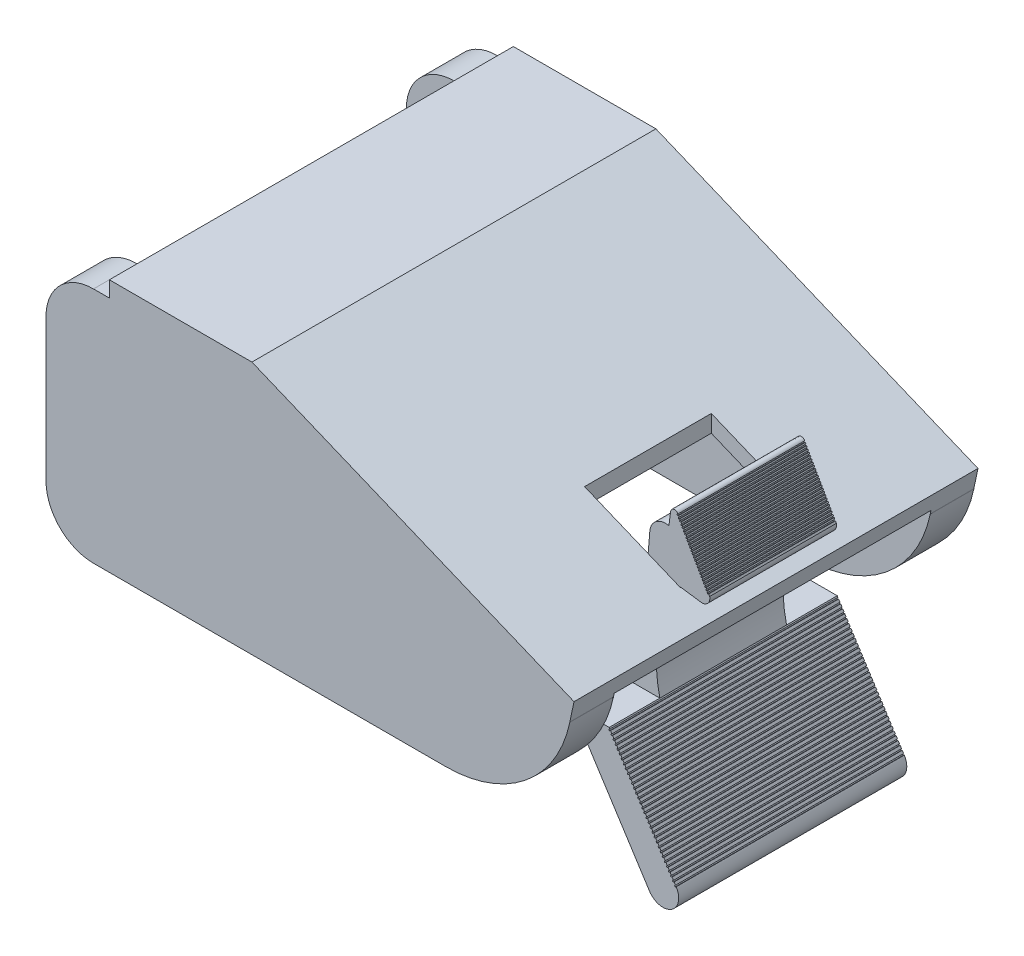
from build123d import *

# Parameters (mm, degrees)
RESSALTO_EXTRUS_O1_DEPTH      = 3.175
RESSALTO_EXTRUS_O2_DEPTH      = 37.3126
RESSALTO_EXTRUS_O2_DEPTH_BACK = 37.3126
RESSALTO_EXTRUS_O3_START      = -3.175
RESSALTO_EXTRUS_O3_DEPTH      = 3.175
CORTE_EXTRUS_O1_DEPTH         = 31.75
CORTE_EXTRUS_O1_DEPTH_BACK    = 31.75
RESSALTO_EXTRUS_O4_DEPTH      = 12.7
RESSALTO_EXTRUS_O4_DEPTH_BACK = 12.7
RESSALTO_EXTRUS_O5_DEPTH      = 12.7
RESSALTO_EXTRUS_O5_DEPTH_BACK = 12.7
RESSALTO_EXTRUS_O6_DEPTH      = 22.86
RESSALTO_EXTRUS_O6_DEPTH_BACK = 22.86
CORTE_EXTRUS_O2_DEPTH         = 12.7
CORTE_EXTRUS_O2_DEPTH_BACK    = 12.7
ESBO_O9_R                     = 2.54
RESSALTO_EXTRUS_O7_DEPTH      = 63.5


with BuildPart() as part:
    # Esboço1 → Ressalto-extrusão1 (new body)
    with BuildSketch(Plane.XY.offset(-40.4876)):
        with BuildLine():
            Line((79.375, -65.0875), (150.000604013, -65.0875))
            ThreePointArc((150.000604013, -65.0875), (165.991768653, -59.421801443), (174.848986961, -44.952275862))
            Line((174.848986961, -44.952275862), (174.848986961, -44.899230051))
            Line((174.848986961, -44.899230051), (175.685365082, -40.951741232))
            Line((175.685365082, -40.951741232), (111.125, -14.2875))
            Line((111.125, -14.2875), (82.55, -14.2875))
            Line((82.55, -14.2875), (82.55, -17.4625))
            Line((82.55, -17.4625), (79.375, -17.4625))
            ThreePointArc((79.375, -17.4625), (72.639807909, -20.252307909), (69.85, -26.9875))
            Line((69.85, -26.9875), (69.85, -55.5625))
            ThreePointArc((69.85, -55.5625), (72.639807909, -62.297692091), (79.375, -65.0875))
        make_face()
    extrude(amount=RESSALTO_EXTRUS_O1_DEPTH)

    # Esboço2 → Ressalto-extrusão2 (add, two sides: drawn at the far end of the back side and taken through both)
    with BuildSketch(Plane.XY.offset(-RESSALTO_EXTRUS_O2_DEPTH_BACK)):
        with BuildLine():
            Line((79.375, -65.0875), (150.000604013, -65.0875))
            ThreePointArc((150.000604013, -65.0875), (165.991768653, -59.421801443), (174.848986961, -44.952275862))
            Line((174.848986961, -44.952275862), (174.848986961, -44.899230051))
            Line((174.848986961, -44.899230051), (175.685365082, -40.951741232))
            Line((175.685365082, -40.951741232), (111.125, -14.2875))
            Line((111.125, -14.2875), (82.55, -14.2875))
            Line((82.55, -14.2875), (82.55, -17.4625))
            Line((82.55, -17.4625), (79.375, -17.4625))
            ThreePointArc((79.375, -17.4625), (72.639807909, -20.252307909), (69.85, -26.9875))
            Line((69.85, -26.9875), (69.85, -55.5625))
            ThreePointArc((69.85, -55.5625), (72.639807909, -62.297692091), (79.375, -65.0875))
        make_face()
    extrude(amount=RESSALTO_EXTRUS_O2_DEPTH + RESSALTO_EXTRUS_O2_DEPTH_BACK)

    # Esboço3 → Ressalto-extrusão3 (add)
    with BuildSketch(Plane.XY.offset(40.4876).offset(RESSALTO_EXTRUS_O3_START)):
        with BuildLine():
            Line((79.375, -65.0875), (150.000604013, -65.0875))
            ThreePointArc((150.000604013, -65.0875), (165.991768653, -59.421801443), (174.848986961, -44.952275862))
            Line((174.848986961, -44.952275862), (174.848986961, -44.899230051))
            Line((174.848986961, -44.899230051), (175.685365082, -40.951741232))
            Line((175.685365082, -40.951741232), (111.125, -14.2875))
            Line((111.125, -14.2875), (82.55, -14.2875))
            Line((82.55, -14.2875), (82.55, -17.4625))
            Line((82.55, -17.4625), (79.375, -17.4625))
            ThreePointArc((79.375, -17.4625), (72.639807909, -20.252307909), (69.85, -26.9875))
            Line((69.85, -26.9875), (69.85, -55.5625))
            ThreePointArc((69.85, -55.5625), (72.639807909, -62.297692091), (79.375, -65.0875))
        make_face()
    extrude(amount=RESSALTO_EXTRUS_O3_DEPTH)

    # Esboço4 → Corte-extrusão1 (cut, two sides: drawn at the far end of the back side and taken through both)
    with BuildSketch(Plane.XY.offset(-CORTE_EXTRUS_O1_DEPTH_BACK)):
        with BuildLine():
            Line((79.375, -65.0875), (150.000604013, -65.0875))
            ThreePointArc((150.000604013, -65.0875), (166.323156329, -59.148596729), (175.012790586, -44.109097315))
            Line((175.012790586, -44.109097315), (110.495145555, -17.4625))
            Line((110.495145555, -17.4625), (79.375, -17.4625))
            ThreePointArc((79.375, -17.4625), (72.639807909, -20.252307909), (69.85, -26.9875))
            Line((69.85, -26.9875), (69.85, -55.5625))
            ThreePointArc((69.85, -55.5625), (72.639807909, -62.297692091), (79.375, -65.0875))
        make_face()
    extrude(amount=CORTE_EXTRUS_O1_DEPTH + CORTE_EXTRUS_O1_DEPTH_BACK, mode=Mode.SUBTRACT)

    # Esboço5 → Ressalto-extrusão4 (add, two sides: drawn at the far end of the back side and taken through both)
    with BuildSketch(Plane.XY.offset(-RESSALTO_EXTRUS_O4_DEPTH_BACK)):
        with BuildLine():
            Line((162.71875, -36.068), (169.153635383, -38.725688443))
            Line((169.153635383, -38.725688443), (169.259167523, -38.1761681))
            Line((169.259167523, -38.1761681), (173.209862682, -38.735321047))
            ThreePointArc((173.209862682, -38.735321047), (174.651258701, -38.314922041), (175.09762541, -36.881354963))
            Line((175.09762541, -36.881354963), (174.90504008, -36.543560839))
            Line((174.90504008, -36.543560839), (174.684382649, -36.669363454))
            Line((174.684382649, -36.669363454), (174.558580034, -36.448706023))
            Line((174.558580034, -36.448706023), (174.779237465, -36.322903408))
            Line((174.779237465, -36.322903408), (174.65343485, -36.102245976))
            Line((174.65343485, -36.102245976), (174.432777419, -36.228048592))
            Line((174.432777419, -36.228048592), (174.306974804, -36.00739116))
            Line((174.306974804, -36.00739116), (174.527632235, -35.881588545))
            Line((174.527632235, -35.881588545), (174.40182962, -35.660931114))
            Line((174.40182962, -35.660931114), (174.181172188, -35.786733729))
            Line((174.181172188, -35.786733729), (174.055369573, -35.566076297))
            Line((174.055369573, -35.566076297), (174.276027005, -35.440273682))
            Line((174.276027005, -35.440273682), (174.150224389, -35.219616251))
            Line((174.150224389, -35.219616251), (173.929566958, -35.345418866))
            Line((173.929566958, -35.345418866), (173.803764343, -35.124761435))
            Line((173.803764343, -35.124761435), (174.024421774, -34.99895882))
            Line((174.024421774, -34.99895882), (173.898619159, -34.778301388))
            Line((173.898619159, -34.778301388), (173.677961728, -34.904104003))
            Line((173.677961728, -34.904104003), (173.552159113, -34.683446572))
            Line((173.552159113, -34.683446572), (173.772816544, -34.557643957))
            Line((173.772816544, -34.557643957), (173.647013929, -34.336986525))
            Line((173.647013929, -34.336986525), (173.426356497, -34.462789141))
            Line((173.426356497, -34.462789141), (173.300553882, -34.242131709))
            Line((173.300553882, -34.242131709), (173.521211314, -34.116329094))
            Line((173.521211314, -34.116329094), (173.395408698, -33.895671663))
            Line((173.395408698, -33.895671663), (173.174751267, -34.021474278))
            Line((173.174751267, -34.021474278), (173.048948652, -33.800816847))
            Line((173.048948652, -33.800816847), (173.269606083, -33.675014231))
            Line((173.269606083, -33.675014231), (173.143803468, -33.4543568))
            Line((173.143803468, -33.4543568), (172.923146037, -33.580159415))
            Line((172.923146037, -33.580159415), (172.797343421, -33.359501984))
            Line((172.797343421, -33.359501984), (173.018000853, -33.233699369))
            Line((173.018000853, -33.233699369), (172.892198238, -33.013041937))
            Line((172.892198238, -33.013041937), (172.671540806, -33.138844552))
            Line((172.671540806, -33.138844552), (172.545738191, -32.918187121))
            Line((172.545738191, -32.918187121), (172.766395622, -32.792384506))
            Line((172.766395622, -32.792384506), (172.640593007, -32.571727075))
            Line((172.640593007, -32.571727075), (172.419935576, -32.69752969))
            Line((172.419935576, -32.69752969), (172.294132961, -32.476872258))
            Line((172.294132961, -32.476872258), (172.514790392, -32.351069643))
            Line((172.514790392, -32.351069643), (172.388987777, -32.130412212))
            Line((172.388987777, -32.130412212), (172.168330346, -32.256214827))
            Line((172.168330346, -32.256214827), (172.04252773, -32.035557396))
            Line((172.04252773, -32.035557396), (172.263185162, -31.909754781))
            Line((172.263185162, -31.909754781), (172.137382547, -31.689097349))
            Line((172.137382547, -31.689097349), (171.916725115, -31.814899964))
            Line((171.916725115, -31.814899964), (171.7909225, -31.594242533))
            Line((171.7909225, -31.594242533), (172.011579931, -31.468439918))
            Line((172.011579931, -31.468439918), (171.885777316, -31.247782486))
            Line((171.885777316, -31.247782486), (171.665119885, -31.373585102))
            Line((171.665119885, -31.373585102), (171.53931727, -31.15292767))
            Line((171.53931727, -31.15292767), (171.759974701, -31.027125055))
            Line((171.759974701, -31.027125055), (171.634172086, -30.806467624))
            Line((171.634172086, -30.806467624), (171.413514654, -30.932270239))
            Line((171.413514654, -30.932270239), (171.287712039, -30.711612808))
            Line((171.287712039, -30.711612808), (171.508369471, -30.585810192))
            Line((171.508369471, -30.585810192), (171.382566855, -30.365152761))
            Line((171.382566855, -30.365152761), (171.161909424, -30.490955376))
            Line((171.161909424, -30.490955376), (171.036106809, -30.270297945))
            Line((171.036106809, -30.270297945), (171.25676424, -30.14449533))
            Line((171.25676424, -30.14449533), (171.130961625, -29.923837898))
            Line((171.130961625, -29.923837898), (170.910304194, -30.049640513))
            Line((170.910304194, -30.049640513), (170.784501579, -29.828983082))
            Line((170.784501579, -29.828983082), (171.00515901, -29.703180467))
            Line((171.00515901, -29.703180467), (170.879356395, -29.482523036))
            Line((170.879356395, -29.482523036), (170.658698963, -29.608325651))
            Line((170.658698963, -29.608325651), (170.532896348, -29.387668219))
            Line((170.532896348, -29.387668219), (170.75355378, -29.261865604))
            Line((170.75355378, -29.261865604), (170.627751164, -29.041208173))
            Line((170.627751164, -29.041208173), (170.407093733, -29.167010788))
            Line((170.407093733, -29.167010788), (170.281291118, -28.946353357))
            Line((170.281291118, -28.946353357), (170.501948549, -28.820550741))
            Line((170.501948549, -28.820550741), (170.376145934, -28.59989331))
            Line((170.376145934, -28.59989331), (170.155488503, -28.725695925))
            Line((170.155488503, -28.725695925), (170.029685888, -28.505038494))
            Line((170.029685888, -28.505038494), (170.250343319, -28.379235879))
            Line((170.250343319, -28.379235879), (170.124540704, -28.158578447))
            Line((170.124540704, -28.158578447), (169.903883272, -28.284381063))
            Line((169.903883272, -28.284381063), (169.778080657, -28.063723631))
            Line((169.778080657, -28.063723631), (169.998738089, -27.937921016))
            Line((169.998738089, -27.937921016), (169.872935473, -27.717263585))
            Line((169.872935473, -27.717263585), (169.652278042, -27.8430662))
            Line((169.652278042, -27.8430662), (169.526475427, -27.622408768))
            Line((169.526475427, -27.622408768), (169.747132858, -27.496606153))
            Line((169.747132858, -27.496606153), (169.621330243, -27.275948722))
            Line((169.621330243, -27.275948722), (169.400672812, -27.401751337))
            Line((169.400672812, -27.401751337), (169.274870196, -27.181093906))
            Line((169.274870196, -27.181093906), (169.495527628, -27.055291291))
            Line((169.495527628, -27.055291291), (169.369725013, -26.834633859))
            Line((169.369725013, -26.834633859), (169.149067581, -26.960436474))
            Line((169.149067581, -26.960436474), (169.023264966, -26.739779043))
            Line((169.023264966, -26.739779043), (169.243922397, -26.613976428))
            Line((169.243922397, -26.613976428), (169.118119782, -26.393318997))
            Line((169.118119782, -26.393318997), (168.897462351, -26.519121612))
            Line((168.897462351, -26.519121612), (168.771659736, -26.29846418))
            Line((168.771659736, -26.29846418), (168.992317167, -26.172661565))
            Line((168.992317167, -26.172661565), (168.866514552, -25.952004134))
            Line((168.866514552, -25.952004134), (168.645857121, -26.077806749))
            Line((168.645857121, -26.077806749), (168.520054505, -25.857149318))
            Line((168.520054505, -25.857149318), (168.740711937, -25.731346702))
            ThreePointArc((168.740711937, -25.731346702), (167.898066698, -25.345633112), (167.264104275, -26.021589929))
            ThreePointArc((167.264104275, -26.021589929), (167.260662371, -26.05267061), (167.258447358, -26.083862744))
            Line((167.258447358, -26.083862744), (166.918435347, -28.684773204))
            ThreePointArc((166.918435347, -28.684773204), (164.36544966, -29.243268954), (163.096256706, -31.52773884))
            Line((163.096256706, -31.52773884), (162.71875, -36.068))
        make_face()
    extrude(amount=RESSALTO_EXTRUS_O4_DEPTH + RESSALTO_EXTRUS_O4_DEPTH_BACK)

    # Esboço6 → Ressalto-extrusão5 (add, two sides: drawn at the far end of the back side and taken through both)
    with BuildSketch(Plane.XY.offset(-RESSALTO_EXTRUS_O5_DEPTH_BACK)):
        with BuildLine():
            Line((158.049164125, -59.53125), (165.1, -59.53125))
            ThreePointArc((165.1, -59.53125), (164.886056969, -48.691892351), (169.153635383, -38.725688443))
            Line((169.153635383, -38.725688443), (162.71875, -36.068))
            ThreePointArc((162.71875, -36.068), (156.944244189, -47.115063626), (158.049164125, -59.53125))
        make_face()
    extrude(amount=RESSALTO_EXTRUS_O5_DEPTH + RESSALTO_EXTRUS_O5_DEPTH_BACK)

    # Esboço7 → Ressalto-extrusão6 (add, two sides: drawn at the far end of the back side and taken through both)
    with BuildSketch(Plane.XY.offset(-RESSALTO_EXTRUS_O6_DEPTH_BACK)):
        with BuildLine():
            Line((159.663348254, -62.816649688), (173.192607564, -83.916071284))
            ThreePointArc((173.192607564, -83.916071284), (177.580626883, -84.874057369), (178.53617499, -80.485506504))
            Line((178.53617499, -80.485506504), (178.322357707, -80.622609289))
            Line((178.322357707, -80.622609289), (178.185253864, -80.408790356))
            Line((178.185253864, -80.408790356), (178.399072797, -80.271686513))
            Line((178.399072797, -80.271686513), (178.124865111, -79.844048646))
            Line((178.124865111, -79.844048646), (177.911046177, -79.98115249))
            Line((177.911046177, -79.98115249), (177.773942334, -79.767333557))
            Line((177.773942334, -79.767333557), (177.987761267, -79.630229713))
            Line((177.987761267, -79.630229713), (177.713553581, -79.202591847))
            Line((177.713553581, -79.202591847), (177.499734648, -79.33969569))
            Line((177.499734648, -79.33969569), (177.362630804, -79.125876757))
            Line((177.362630804, -79.125876757), (177.576449737, -78.988772914))
            Line((177.576449737, -78.988772914), (177.302242051, -78.561135048))
            Line((177.302242051, -78.561135048), (177.088423118, -78.698238891))
            Line((177.088423118, -78.698238891), (176.951319275, -78.484419958))
            Line((176.951319275, -78.484419958), (177.165138208, -78.347316115))
            Line((177.165138208, -78.347316115), (176.890930521, -77.919678248))
            Line((176.890930521, -77.919678248), (176.677111588, -78.056782092))
            Line((176.677111588, -78.056782092), (176.540007745, -77.842963159))
            Line((176.540007745, -77.842963159), (176.753826678, -77.705859315))
            Line((176.753826678, -77.705859315), (176.479618991, -77.278221449))
            Line((176.479618991, -77.278221449), (176.265800058, -77.415325292))
            Line((176.265800058, -77.415325292), (176.128696215, -77.201506359))
            Line((176.128696215, -77.201506359), (176.342515148, -77.064402516))
            Line((176.342515148, -77.064402516), (176.068307462, -76.63676465))
            Line((176.068307462, -76.63676465), (175.854488528, -76.773868493))
            Line((175.854488528, -76.773868493), (175.717384685, -76.56004956))
            Line((175.717384685, -76.56004956), (175.931203618, -76.422945717))
            Line((175.931203618, -76.422945717), (175.656995932, -75.99530785))
            Line((175.656995932, -75.99530785), (175.443176999, -76.132411694))
            Line((175.443176999, -76.132411694), (175.306073155, -75.91859276))
            Line((175.306073155, -75.91859276), (175.519892088, -75.781488917))
            Line((175.519892088, -75.781488917), (175.245684402, -75.353851051))
            Line((175.245684402, -75.353851051), (175.031865469, -75.490954894))
            Line((175.031865469, -75.490954894), (174.894761625, -75.277135961))
            Line((174.894761625, -75.277135961), (175.108580559, -75.140032118))
            Line((175.108580559, -75.140032118), (174.834372872, -74.712394252))
            Line((174.834372872, -74.712394252), (174.620553939, -74.849498095))
            Line((174.620553939, -74.849498095), (174.483450096, -74.635679162))
            Line((174.483450096, -74.635679162), (174.697269029, -74.498575318))
            Line((174.697269029, -74.498575318), (174.423061342, -74.070937452))
            Line((174.423061342, -74.070937452), (174.209242409, -74.208041295))
            Line((174.209242409, -74.208041295), (174.072138566, -73.994222362))
            Line((174.072138566, -73.994222362), (174.285957499, -73.857118519))
            Line((174.285957499, -73.857118519), (174.011749812, -73.429480653))
            Line((174.011749812, -73.429480653), (173.797930879, -73.566584496))
            Line((173.797930879, -73.566584496), (173.660827036, -73.352765563))
            Line((173.660827036, -73.352765563), (173.874645969, -73.21566172))
            Line((173.874645969, -73.21566172), (173.600438283, -72.788023853))
            Line((173.600438283, -72.788023853), (173.38661935, -72.925127697))
            Line((173.38661935, -72.925127697), (173.249515506, -72.711308764))
            Line((173.249515506, -72.711308764), (173.463334439, -72.57420492))
            Line((173.463334439, -72.57420492), (173.189126753, -72.146567054))
            Line((173.189126753, -72.146567054), (172.97530782, -72.283670897))
            Line((172.97530782, -72.283670897), (172.838203976, -72.069851964))
            Line((172.838203976, -72.069851964), (173.05202291, -71.932748121))
            Line((173.05202291, -71.932748121), (172.777815223, -71.505110255))
            Line((172.777815223, -71.505110255), (172.56399629, -71.642214098))
            Line((172.56399629, -71.642214098), (172.426892447, -71.428395165))
            Line((172.426892447, -71.428395165), (172.64071138, -71.291291322))
            Line((172.64071138, -71.291291322), (172.366503693, -70.863653455))
            Line((172.366503693, -70.863653455), (172.15268476, -71.000757299))
            Line((172.15268476, -71.000757299), (172.015580917, -70.786938366))
            Line((172.015580917, -70.786938366), (172.22939985, -70.649834522))
            Line((172.22939985, -70.649834522), (171.955192163, -70.222196656))
            Line((171.955192163, -70.222196656), (171.74137323, -70.359300499))
            Line((171.74137323, -70.359300499), (171.604269387, -70.145481566))
            Line((171.604269387, -70.145481566), (171.81808832, -70.008377723))
            Line((171.81808832, -70.008377723), (171.543880634, -69.580739857))
            Line((171.543880634, -69.580739857), (171.330061701, -69.7178437))
            Line((171.330061701, -69.7178437), (171.192957857, -69.504024767))
            Line((171.192957857, -69.504024767), (171.40677679, -69.366920924))
            Line((171.40677679, -69.366920924), (171.132569104, -68.939283057))
            Line((171.132569104, -68.939283057), (170.918750171, -69.076386901))
            Line((170.918750171, -69.076386901), (170.781646327, -68.862567967))
            Line((170.781646327, -68.862567967), (170.995465261, -68.725464124))
            Line((170.995465261, -68.725464124), (170.721257574, -68.297826258))
            Line((170.721257574, -68.297826258), (170.507438641, -68.434930101))
            Line((170.507438641, -68.434930101), (170.370334798, -68.221111168))
            Line((170.370334798, -68.221111168), (170.584153731, -68.084007325))
            Line((170.584153731, -68.084007325), (170.309946044, -67.656369459))
            Line((170.309946044, -67.656369459), (170.096127111, -67.793473302))
            Line((170.096127111, -67.793473302), (169.959023268, -67.579654369))
            Line((169.959023268, -67.579654369), (170.172842201, -67.442550525))
            Line((170.172842201, -67.442550525), (169.898634514, -67.014912659))
            Line((169.898634514, -67.014912659), (169.684815581, -67.152016502))
            Line((169.684815581, -67.152016502), (169.547711738, -66.938197569))
            Line((169.547711738, -66.938197569), (169.761530671, -66.801093726))
            Line((169.761530671, -66.801093726), (169.487322985, -66.37345586))
            Line((169.487322985, -66.37345586), (169.273504051, -66.510559703))
            Line((169.273504051, -66.510559703), (169.136400208, -66.29674077))
            Line((169.136400208, -66.29674077), (169.350219141, -66.159636927))
            Line((169.350219141, -66.159636927), (169.076011455, -65.731999061))
            Line((169.076011455, -65.731999061), (168.862192522, -65.869102904))
            Line((168.862192522, -65.869102904), (168.725088678, -65.655283971))
            Line((168.725088678, -65.655283971), (168.938907612, -65.518180127))
            Line((168.938907612, -65.518180127), (168.664699925, -65.090542261))
            Line((168.664699925, -65.090542261), (168.450880992, -65.227646104))
            Line((168.450880992, -65.227646104), (168.313777149, -65.013827171))
            Line((168.313777149, -65.013827171), (168.527596082, -64.876723328))
            Line((168.527596082, -64.876723328), (168.253388395, -64.449085462))
            Line((168.253388395, -64.449085462), (168.039569462, -64.586189305))
            Line((168.039569462, -64.586189305), (167.902465619, -64.372370372))
            Line((167.902465619, -64.372370372), (168.116284552, -64.235266529))
            Line((168.116284552, -64.235266529), (167.842076865, -63.807628662))
            Line((167.842076865, -63.807628662), (167.628257932, -63.944732506))
            Line((167.628257932, -63.944732506), (167.491154089, -63.730913573))
            Line((167.491154089, -63.730913573), (167.704973022, -63.593809729))
            Line((167.704973022, -63.593809729), (167.430765336, -63.166171863))
            Line((167.430765336, -63.166171863), (167.216946402, -63.303275706))
            Line((167.216946402, -63.303275706), (167.079842559, -63.089456773))
            Line((167.079842559, -63.089456773), (167.293661492, -62.95235293))
            Line((167.293661492, -62.95235293), (167.019453806, -62.524715064))
            Line((167.019453806, -62.524715064), (166.805634873, -62.661818907))
            Line((166.805634873, -62.661818907), (166.668531029, -62.447999974))
            Line((166.668531029, -62.447999974), (166.882349962, -62.310896131))
            Line((166.882349962, -62.310896131), (166.608142276, -61.883258264))
            Line((166.608142276, -61.883258264), (166.394323343, -62.020362108))
            Line((166.394323343, -62.020362108), (166.2572195, -61.806543174))
            Line((166.2572195, -61.806543174), (166.471038433, -61.669439331))
            Line((166.471038433, -61.669439331), (166.196830746, -61.241801465))
            Line((166.196830746, -61.241801465), (165.983011813, -61.378905308))
            Line((165.983011813, -61.378905308), (165.84590797, -61.165086375))
            Line((165.84590797, -61.165086375), (166.059726903, -61.027982532))
            Line((166.059726903, -61.027982532), (165.785519216, -60.600344666))
            Line((165.785519216, -60.600344666), (165.571700283, -60.737448509))
            Line((165.571700283, -60.737448509), (165.43459644, -60.523629576))
            Line((165.43459644, -60.523629576), (165.648415373, -60.386525732))
            Line((165.648415373, -60.386525732), (165.374207687, -59.958887866))
            Line((165.374207687, -59.958887866), (165.160388753, -60.09599171))
            Line((165.160388753, -60.09599171), (165.02328491, -59.882172776))
            Line((165.02328491, -59.882172776), (165.237103843, -59.745068933))
            Line((165.237103843, -59.745068933), (165.1, -59.53125))
            Line((165.1, -59.53125), (158.049164125, -59.53125))
            ThreePointArc((158.049164125, -59.53125), (158.78827803, -61.207348906), (159.663348254, -62.816649688))
        make_face()
    extrude(amount=RESSALTO_EXTRUS_O6_DEPTH + RESSALTO_EXTRUS_O6_DEPTH_BACK)

    # Esboço8 → Corte-extrusão2 (cut, two sides: drawn at the far end of the back side and taken through both)
    with BuildSketch(Plane.XY.offset(-CORTE_EXTRUS_O2_DEPTH_BACK)):
        Polygon((150.01875, -30.273118525), (150.01875, -34.257878364), (162.71875, -39.503137793), (162.71875, -35.518377953), align=None)
    extrude(amount=CORTE_EXTRUS_O2_DEPTH + CORTE_EXTRUS_O2_DEPTH_BACK, mode=Mode.SUBTRACT)

    # Esboço9 → Ressalto-extrusão7 (add)
    with BuildSketch(Plane.XY.offset(-31.75)):
        with Locations((161.743756941, -49.621260784)):
            Circle(ESBO_O9_R)
    extrude(amount=RESSALTO_EXTRUS_O7_DEPTH)


solid = part.part
